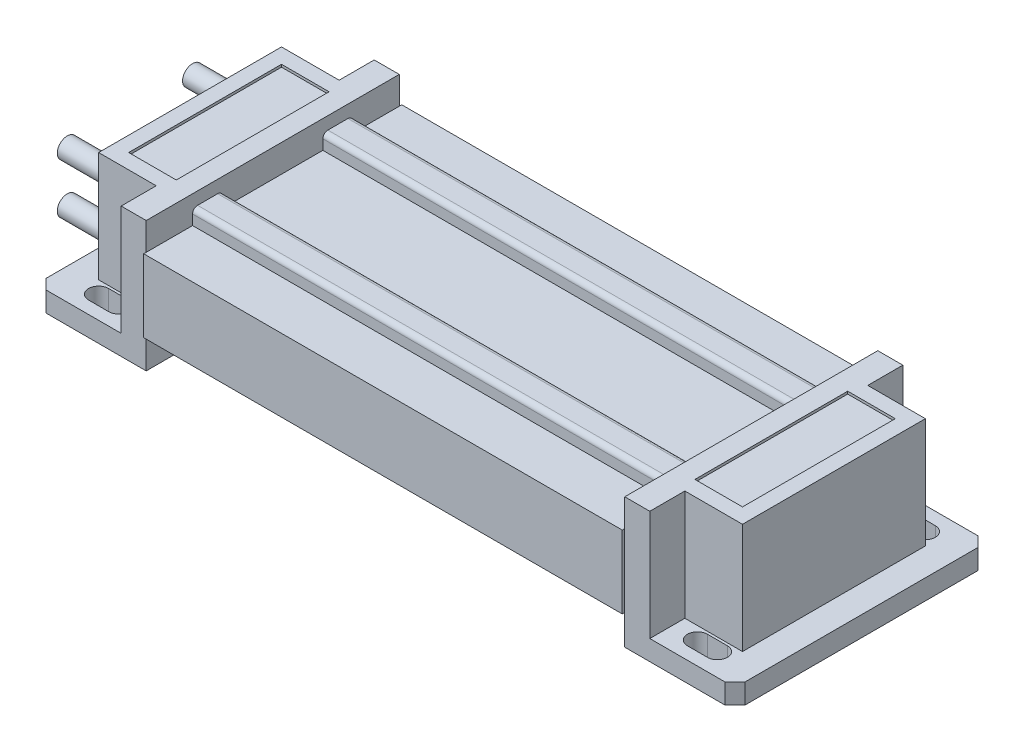
from build123d import *

# Parameters (mm, degrees)
SKETCH1_W             = 22
SKETCH1_H             = 50.5
BOSS_EXTRUDE1_DEPTH   = 26
BOSS_EXTRUDE1_2_DEPTH = 26
CHAMFER1_SIZE         = 2
CUT_EXTRUDE4_DEPTH    = 22
CHAMFER2_SIZE         = 2
SKETCH5_W             = 9.5
SKETCH5_H             = 30.5
CUT_EXTRUDE5_DEPTH    = 0.5
SKETCH6_W             = 51.5
SKETCH6_H             = 20.5
BOSS_EXTRUDE2_DEPTH   = 95.5
SKETCH7_R             = 2
BOSS_EXTRUDE3_DEPTH   = 12
CUT_EXTRUDE7_DEPTH    = 5
SKETCH15_W            = 95.5
SKETCH15_H            = 20
SKETCH15_H_2          = 9.75
CUT_EXTRUDE8_DEPTH    = 3
FILLET3_R             = 1
SKETCH16_W            = 95.5
SKETCH16_H            = 9.75
SKETCH16_H_2          = 20
CUT_EXTRUDE9_DEPTH    = 3
FILLET4_R             = 1
CUT_EXTRUDE10_DEPTH   = 0.1


with BuildPart() as part:
    # Sketch1 → Boss-Extrude1 (new body)
    with BuildSketch(Plane(origin=(0, 0, 0), x_dir=(1, 0, 0), z_dir=(0, 1, 0))):
        with Locations((11, 25.25)):
            Rectangle(SKETCH1_W, SKETCH1_H)
    extrude(amount=BOSS_EXTRUDE1_DEPTH)

    # Chamfer1
    chamfer1_edges = [part.edges().sort_by_distance(p)[0] for p in [
        (22, 13, -50.5),
        (22, 13, 0),
    ]]
    chamfer(chamfer1_edges, length=CHAMFER1_SIZE)


with BuildPart() as body_2:
    # Sketch1 → Boss-Extrude1 2 (new body)
    with BuildSketch(Plane(origin=(0, 0, 0), x_dir=(1, 0, 0), z_dir=(0, 1, 0))):
        with Locations((-106.5, 25.25)):
            Rectangle(SKETCH1_W, SKETCH1_H)
    extrude(amount=BOSS_EXTRUDE1_2_DEPTH)


with BuildPart() as cut_extrude4_tool:
    # Sketch2 → Cut-Extrude4 (new body)
    with BuildSketch(Plane(origin=(0, 26, 0), x_dir=(1, 0, 0), z_dir=(0, 1, 0))):
        Polygon((22, 50.5), (5, 50.5), (5, 43.5), (16.5, 43.5), (16.5, 7), (5, 7), (5, 0), (22, 0), align=None)
        Polygon((-117.5, 0), (-117.5, 50.5), (-100.5, 50.5), (-100.5, 43.5), (-112, 43.5), (-112, 7), (-100.5, 7), (-100.5, 0), align=None)
    extrude(amount=-CUT_EXTRUDE4_DEPTH)


with BuildPart() as part_1:
    add(part.part)

    # Cut-Extrude4: cut by cut_extrude4_tool
    add(cut_extrude4_tool.part, mode=Mode.SUBTRACT)


with BuildPart() as body_2_1:
    add(body_2.part)

    # Cut-Extrude4: cut by cut_extrude4_tool
    add(cut_extrude4_tool.part, mode=Mode.SUBTRACT)

    # Chamfer2
    chamfer2_edges = [body_2_1.edges().sort_by_distance(p)[0] for p in [
        (-117.5, 2, 0),
        (-117.5, 2, -50.5),
    ]]
    chamfer(chamfer2_edges, length=CHAMFER2_SIZE)


with BuildPart() as cut_extrude5_tool:
    # Sketch5 → Cut-Extrude5 (new body)
    with BuildSketch(Plane(origin=(0, 26, 0), x_dir=(1, 0, 0), z_dir=(0, 1, 0))):
        with Locations((8.75, 25.25)):
            Rectangle(SKETCH5_W, SKETCH5_H)
        with Locations((-104.25, 25.25)):
            Rectangle(SKETCH5_W, SKETCH5_H)
    extrude(amount=-CUT_EXTRUDE5_DEPTH)


with BuildPart() as part_2:
    add(part_1.part)

    # Cut-Extrude5: cut by cut_extrude5_tool
    add(cut_extrude5_tool.part, mode=Mode.SUBTRACT)



with BuildPart() as body_2_2:
    add(body_2_1.part)

    # Cut-Extrude5: cut by cut_extrude5_tool
    add(cut_extrude5_tool.part, mode=Mode.SUBTRACT)


with BuildPart() as part_3:
    add(part_2.part)

    add(body_2_2.part)  # Boss-Extrude2 merges body 2
    # Sketch6 → Boss-Extrude2 (add)
    with BuildSketch(Plane.ZY):
        with Locations((-25.25, 13.25)):
            Rectangle(SKETCH6_W, SKETCH6_H)
    extrude(amount=BOSS_EXTRUDE2_DEPTH)

    # Sketch7 → Boss-Extrude3 (add)
    with BuildSketch(Plane.ZY.offset(112)):
        with Locations((-37.75, 18)):
            Circle(SKETCH7_R)
        with Locations((-37.75, 8)):
            Circle(SKETCH7_R)
        with Locations((-12.75, 8)):
            Circle(SKETCH7_R)
        with Locations((-12.75, 18)):
            Circle(SKETCH7_R)
    extrude(amount=BOSS_EXTRUDE3_DEPTH)

    # Sketch14 → Cut-Extrude7 (cut, through all)
    with BuildSketch(Plane(origin=(0, 4, 0), x_dir=(1, 0, 0), z_dir=(0, 1, 0))):
        with BuildLine():
            Line((10, 6.5), (14, 6.5))
            ThreePointArc((14, 6.5), (16, 4.5), (14, 2.5))
            Line((14, 2.5), (10, 2.5))
            ThreePointArc((10, 2.5), (8, 4.5), (10, 6.5))
        make_face()
        with BuildLine():
            Line((14, 48), (10, 48))
            ThreePointArc((10, 48), (8, 46), (10, 44))
            Line((10, 44), (14, 44))
            ThreePointArc((14, 44), (16, 46), (14, 48))
        make_face()
        with BuildLine():
            Line((-105.5, 44), (-109.5, 44))
            ThreePointArc((-109.5, 44), (-111.5, 46), (-109.5, 48))
            Line((-109.5, 48), (-105.5, 48))
            ThreePointArc((-105.5, 48), (-103.5, 46), (-105.5, 44))
        make_face()
        with BuildLine():
            Line((-109.5, 2.5), (-105.5, 2.5))
            ThreePointArc((-105.5, 2.5), (-103.5, 4.5), (-105.5, 6.5))
            Line((-105.5, 6.5), (-109.5, 6.5))
            ThreePointArc((-109.5, 6.5), (-111.5, 4.5), (-109.5, 2.5))
        make_face()
    extrude(amount=-CUT_EXTRUDE7_DEPTH, mode=Mode.SUBTRACT)

    # Sketch15 → Cut-Extrude8 (cut)
    with BuildSketch(Plane(origin=(0, 23.5, 0), x_dir=(1, 0, 0), z_dir=(0, 1, 0))):
        with Locations((-47.75, 25.25)):
            Rectangle(SKETCH15_W, SKETCH15_H)
        with Locations((-47.75, 46.125)):
            Rectangle(SKETCH15_W, SKETCH15_H_2)
        with Locations((-47.75, 4.375)):
            Rectangle(SKETCH15_W, SKETCH15_H_2)
    extrude(amount=-CUT_EXTRUDE8_DEPTH, mode=Mode.SUBTRACT)

    # Fillet3
    fillet3_edges = [part_3.edges().sort_by_distance(p)[0] for p in [
        (-47.75, 23.5, -9.25),
        (-47.75, 23.5, -41.25),
        (-47.75, 23.5, -15.25),
        (-47.75, 23.5, -35.25),
    ]]
    fillet(fillet3_edges, radius=FILLET3_R)

    # Sketch16 → Cut-Extrude9 (cut)
    with BuildSketch(Plane.XZ.offset(-3)):
        with Locations((-47.75, -4.375)):
            Rectangle(SKETCH16_W, SKETCH16_H)
        with Locations((-47.75, -25.25)):
            Rectangle(SKETCH16_W, SKETCH16_H_2)
        with Locations((-47.75, -46.125)):
            Rectangle(SKETCH16_W, SKETCH16_H)
    extrude(amount=-CUT_EXTRUDE9_DEPTH, mode=Mode.SUBTRACT)

    # Fillet4
    fillet4_edges = [part_3.edges().sort_by_distance(p)[0] for p in [
        (-47.75, 3, -9.25),
        (-47.75, 3, -15.25),
        (-47.75, 3, -35.25),
        (-47.75, 3, -41.25),
    ]]
    fillet(fillet4_edges, radius=FILLET4_R)

    # Sketch17 → Cut-Extrude10 (cut)
    with BuildSketch(Plane(origin=(0, 0, -51), x_dir=(-1, 0, 0), z_dir=(0, 0, -1))):
        Polygon((27.949136007, 14.272391854), (28.842365174, 14.272391854), (28.842365174, 10.772391854), (28.393647225, 10.772391854), (28.393647225, 13.913417495), (27.675698507, 13.913417495), align=None)
        Polygon((32.490161648, 14.272391854), (33.383390815, 14.272391854), (33.383390815, 10.772391854), (32.934672866, 10.772391854), (32.934672866, 13.913417495), (32.216724148, 13.913417495), align=None)
        with BuildLine():
            add(Edge.make_bspline(
                [(36.039801071, 12.520989611), (36.040235983, 12.577094028), (36.041081058, 12.68611009), (36.050574892, 12.844910803), (36.064868155, 12.993962436), (36.085180208, 13.133192187), (36.110637379, 13.262589071), (36.143023474, 13.381959165), (36.180368413, 13.49196332), (36.225174876, 13.592138896), (36.274712189, 13.684710107), (36.328469097, 13.771188768), (36.38799451, 13.851434251), (36.45138155, 13.926720723), (36.52062727, 13.995281683), (36.593483365, 14.059255742), (36.672666025, 14.115462843), (36.755053625, 14.167883856), (36.842062471, 14.212770811), (36.931049243, 14.253052657), (37.022816498, 14.287065778), (37.117416889, 14.313958722), (37.214249595, 14.336003342), (37.313575351, 14.351316575), (37.415450847, 14.360724191), (37.484325108, 14.361661345), (37.519168058, 14.362135444)],
                knots=[0, 0, 0, 0, 0.000168293, 0.000327008, 0.000477071, 0.000617374, 0.000748963, 0.00087244, 0.000988183, 0.0010971, 0.001201238, 0.00130298, 0.001402263, 0.001500745, 0.001597915, 0.001694344, 0.001791254, 0.001888909, 0.001987068, 0.002084668, 0.002181828, 0.00228035, 0.002379516, 0.002479571, 0.002581641, 0.002686146, 0.002686146, 0.002686146, 0.002686146], degree=3))
            add(Edge.make_bspline(
                [(37.519168058, 14.362135444), (37.554478547, 14.36166435), (37.624286205, 14.360733013), (37.727785254, 14.351257617), (37.82875767, 14.336062357), (37.927025202, 14.314092082), (38.022899073, 14.286801802), (38.116177667, 14.253173476), (38.207012175, 14.212974768), (38.294994804, 14.166718619), (38.38028797, 14.115300464), (38.460035266, 14.056036025), (38.53531424, 13.991199698), (38.606734448, 13.920830483), (38.673025877, 13.843712168), (38.734978515, 13.760466194), (38.792618744, 13.671362711), (38.845184505, 13.575494404), (38.893631875, 13.472962641), (38.933694767, 13.361411477), (38.968875408, 13.242086643), (38.997662627, 13.114243633), (39.018784732, 12.977612284), (39.035179767, 12.832859287), (39.043915908, 12.679550087), (39.045433031, 12.574751944), (39.046211327, 12.520989611)],
                knots=[0, 0, 0, 0, 0.000105907, 0.000209374, 0.000311507, 0.000412041, 0.000511237, 0.000610373, 0.000709254, 0.000808981, 0.000908424, 0.001007706, 0.001106644, 0.001206295, 0.001308199, 0.001411404, 0.001517394, 0.001626285, 0.001739207, 0.001857212, 0.001981452, 0.002112254, 0.002249997, 0.002396022, 0.002549138, 0.002710434, 0.002710434, 0.002710434, 0.002710434], degree=3))
            add(Edge.make_bspline(
                [(39.046211327, 12.520989611), (39.045843029, 12.467451311), (39.045125059, 12.363082493), (39.034618126, 12.210608827), (39.019851972, 12.066399915), (38.998088561, 11.930638042), (38.970361122, 11.803398042), (38.935621992, 11.684616104), (38.896604041, 11.573415137), (38.848672365, 11.471409879), (38.796826082, 11.376236328), (38.739730755, 11.287542192), (38.677963516, 11.204542607), (38.611382143, 11.127489786), (38.540424072, 11.056160101), (38.464198069, 10.991556436), (38.383588229, 10.932368046), (38.298157294, 10.880186788), (38.20946177, 10.833950919), (38.118465766, 10.792785454), (38.024144578, 10.759635101), (37.928067591, 10.731275118), (37.829447857, 10.709416769), (37.728218641, 10.694402009), (37.624558946, 10.683843515), (37.554484796, 10.683048796), (37.519168058, 10.682648264)],
                knots=[0, 0, 0, 0, 0.000160581, 0.000313041, 0.000458294, 0.000595344, 0.000725309, 0.000848679, 0.000966444, 0.001078435, 0.001186374, 0.001291395, 0.0013946, 0.001496505, 0.00159665, 0.00169612, 0.001795968, 0.001896375, 0.001996102, 0.002095908, 0.002195704, 0.002295768, 0.002396303, 0.002498436, 0.002602665, 0.002708572, 0.002708572, 0.002708572, 0.002708572], degree=3))
            add(Edge.make_bspline(
                [(37.519168058, 10.682648264), (37.484325774, 10.683125714), (37.41545283, 10.684069492), (37.313567698, 10.693428635), (37.214553182, 10.708878131), (37.118139153, 10.730115006), (37.023897476, 10.756267868), (36.93279393, 10.790349307), (36.844150014, 10.829852623), (36.75790675, 10.874148524), (36.675929863, 10.925708301), (36.597686563, 10.98232147), (36.524517882, 11.045912111), (36.456117601, 11.115277112), (36.391673175, 11.18988494), (36.332814932, 11.27106257), (36.278164698, 11.357917396), (36.227981112, 11.451238123), (36.182517558, 11.552110179), (36.144209784, 11.662686304), (36.112348706, 11.782788589), (36.085891276, 11.912029559), (36.064673116, 12.050760286), (36.050630588, 12.199177667), (36.041078698, 12.357035513), (36.040234632, 12.465351995), (36.039801071, 12.520989611)],
                knots=[0, 0, 0, 0, 0.000104505, 0.000206575, 0.000306629, 0.000404959, 0.000502614, 0.000599775, 0.000696448, 0.000793662, 0.00089035, 0.000986693, 0.001083122, 0.001180789, 0.001278738, 0.001378586, 0.001481295, 0.001586381, 0.001696225, 0.00181286, 0.001937014, 0.002068743, 0.002208456, 0.002357822, 0.002515837, 0.002682728, 0.002682728, 0.002682728, 0.002682728], degree=3))
        make_face()
        with BuildLine():
            add(Edge.make_bspline(
                [(36.48851902, 12.522391854), (36.488875922, 12.475641221), (36.489568659, 12.384899615), (36.496236038, 12.253043074), (36.505507206, 12.129969204), (36.519547326, 12.015797558), (36.537514851, 11.910430975), (36.559943295, 11.813801107), (36.585421525, 11.725726689), (36.615978361, 11.646118476), (36.65072469, 11.573506871), (36.688634644, 11.50563237), (36.730689437, 11.442650123), (36.776472473, 11.383904049), (36.82647001, 11.330046385), (36.879661382, 11.27978636), (36.937554696, 11.23506405), (37.018331151, 11.181193314), (37.1245234, 11.125503043), (37.257567413, 11.077478682), (37.394194569, 11.047352586), (37.486765943, 11.043536427), (37.533190494, 11.041622623)],
                knots=[0, 0, 0, 0, 0.00014024, 0.000272202, 0.000395989, 0.000510433, 0.00061717, 0.000716492, 0.000807891, 0.000892005, 0.000971976, 0.001049201, 0.001125039, 0.001198953, 0.001272387, 0.001345307, 0.001418237, 0.001491547, 0.001636436, 0.001776604, 0.00191494, 0.002054109, 0.002054109, 0.002054109, 0.002054109], degree=3))
            add(Edge.make_bspline(
                [(37.533190494, 11.041622623), (37.579859929, 11.043210831), (37.672703306, 11.046370383), (37.808643009, 11.07683322), (37.940297023, 11.123134292), (38.04431141, 11.177948226), (38.123227197, 11.230857823), (38.179979715, 11.27509567), (38.232226119, 11.325146024), (38.281423744, 11.379066057), (38.326954481, 11.437613567), (38.366899712, 11.501937143), (38.405580243, 11.569689922), (38.426841082, 11.617967849), (38.437637609, 11.642484002)],
                knots=[0, 0, 0, 0, 0.000139821, 0.000278157, 0.000415871, 0.000557625, 0.000629379, 0.000700773, 0.000773183, 0.000846143, 0.000919627, 0.000995287, 0.001073124, 0.001153432, 0.001153432, 0.001153432, 0.001153432], degree=3))
            add(Edge.make_bspline(
                [(38.437637609, 11.642484002), (38.450345588, 11.673676811), (38.476077088, 11.736836953), (38.509205296, 11.835237826), (38.536182429, 11.938417315), (38.558741933, 12.046045221), (38.576094621, 12.158391522), (38.588874622, 12.275577974), (38.595544538, 12.39751463), (38.596836766, 12.480317641), (38.597493379, 12.522391854)],
                knots=[0, 0, 0, 0, 0.000101032, 0.000204573, 0.000311203, 0.000420796, 0.000534337, 0.000652102, 0.000774299, 0.000900532, 0.000900532, 0.000900532, 0.000900532], degree=3))
            add(Edge.make_bspline(
                [(38.597493379, 12.522391854), (38.597172753, 12.564470465), (38.596545278, 12.646819833), (38.589221816, 12.767261289), (38.578202839, 12.881891439), (38.562750002, 12.990666929), (38.543593037, 13.09379738), (38.518722813, 13.190814503), (38.49039008, 13.282374208), (38.456360186, 13.367785626), (38.419645582, 13.447899513), (38.378347794, 13.521695563), (38.335373765, 13.591037782), (38.287341746, 13.653825663), (38.236926569, 13.712133433), (38.18200663, 13.763699569), (38.124391298, 13.810542334), (38.043464254, 13.863888807), (37.937914197, 13.919110503), (37.806481371, 13.968314473), (37.670687781, 13.997168234), (37.579128579, 14.001158863), (37.533190494, 14.003161085)],
                knots=[0, 0, 0, 0, 0.000126219, 0.000247016, 0.000361848, 0.000471611, 0.000576529, 0.000676347, 0.000771919, 0.000863838, 0.000951981, 0.001036084, 0.00111739, 0.001196477, 0.001272986, 0.001348369, 0.00142217, 0.00149548, 0.001638801, 0.001778551, 0.00191537, 0.00205314, 0.00205314, 0.00205314, 0.00205314], degree=3))
            add(Edge.make_bspline(
                [(37.533190494, 14.003161085), (37.486317378, 14.001182552), (37.393363215, 13.997258919), (37.255924816, 13.968413802), (37.123727747, 13.919277399), (37.018305746, 13.864007662), (36.938003323, 13.811214256), (36.881086978, 13.766093094), (36.827759883, 13.716456909), (36.778744732, 13.661750884), (36.731822285, 13.604067767), (36.691051453, 13.540066466), (36.651857171, 13.472963465), (36.617634736, 13.399862701), (36.585865013, 13.320651794), (36.560855123, 13.232557262), (36.537951282, 13.136044586), (36.520513995, 13.030317331), (36.505314649, 12.916040649), (36.496250342, 12.792669395), (36.48955915, 12.660586849), (36.488872654, 12.569376831), (36.48851902, 12.522391854)],
                knots=[0, 0, 0, 0, 0.000140567, 0.00027876, 0.000419168, 0.000562489, 0.000634827, 0.000707205, 0.000780125, 0.000853086, 0.000927434, 0.001002886, 0.001080457, 0.001160428, 0.001244796, 0.001336195, 0.001434834, 0.001542262, 0.001657489, 0.001780577, 0.001913239, 0.002054181, 0.002054181, 0.002054181, 0.002054181], degree=3))
        make_face(mode=Mode.SUBTRACT)
        Polygon((40.625698507, 14.272391854), (41.113679276, 14.272391854), (42.600057481, 11.576578553), (44.086435686, 14.272391854), (44.574416456, 14.272391854), (42.644929276, 10.772391854), (42.555185686, 10.772391854), align=None)
        with BuildLine():
            Line((51.726980558, 14.272391854), (51.726980558, 13.913417495))
            Line((51.726980558, 13.913417495), (50.251820302, 13.913417495))
            Line((50.251820302, 13.913417495), (50.014140013, 12.985132239))
            add(Edge.make_bspline(
                [(50.014140013, 12.985132239), (50.059359491, 12.996649671), (50.147190161, 13.019020204), (50.27666501, 13.042735849), (50.399408955, 13.057629766), (50.478945507, 13.059800104), (50.517545462, 13.060853393)],
                knots=[0, 0, 0, 0, 0.000139952, 0.000271832, 0.000394631, 0.00051042, 0.00051042, 0.00051042, 0.00051042], degree=3))
            add(Edge.make_bspline(
                [(50.517545462, 13.060853393), (50.565266355, 13.06001131), (50.658865196, 13.058359664), (50.795768939, 13.042455346), (50.92637733, 13.017298979), (51.050561443, 12.982408573), (51.168568881, 12.937492909), (51.279672913, 12.881710842), (51.384857528, 12.816339099), (51.482346489, 12.740916047), (51.57088404, 12.658088923), (51.649180464, 12.569350957), (51.714208913, 12.47404308), (51.769302538, 12.374021545), (51.810578196, 12.26730352), (51.839739731, 12.155065825), (51.85892229, 12.037404397), (51.860694136, 11.956896929), (51.861595943, 11.915921502)],
                knots=[0, 0, 0, 0, 0.000143113, 0.000280699, 0.00041284, 0.000541795, 0.000667186, 0.000791038, 0.000914185, 0.001038154, 0.001160178, 0.001277448, 0.001392385, 0.001505639, 0.001619303, 0.001734605, 0.001853103, 0.001975927, 0.001975927, 0.001975927, 0.001975927], degree=3))
            add(Edge.make_bspline(
                [(51.861595943, 11.915921502), (51.861188474, 11.88737687), (51.860377713, 11.8305803), (51.849835775, 11.746516668), (51.83460967, 11.663984), (51.813077303, 11.583141307), (51.783874905, 11.504669629), (51.749473557, 11.427697438), (51.708585842, 11.352526978), (51.66188973, 11.279492291), (51.610132824, 11.209232944), (51.553129431, 11.143422027), (51.49201874, 11.081295381), (51.425935432, 11.02393309), (51.355692268, 10.970501578), (51.281164209, 10.921399756), (51.202344509, 10.876225626), (51.118968451, 10.836035872), (51.03222174, 10.799082616), (50.941453195, 10.768849719), (50.847820942, 10.741654157), (50.750579996, 10.720285833), (50.650198858, 10.703334062), (50.546494813, 10.691757975), (50.439622739, 10.683437971), (50.367054696, 10.682913546), (50.330345943, 10.682648264)],
                knots=[0, 0, 0, 0, 8.5583e-05, 0.000170288, 0.000253757, 0.000337264, 0.000420886, 0.000504675, 0.000590008, 0.000677336, 0.000764557, 0.000851556, 0.000938317, 0.001025774, 0.001113837, 0.001202899, 0.001293341, 0.001386157, 0.001480431, 0.001575992, 0.001672973, 0.001772823, 0.001874486, 0.001978237, 0.002085786, 0.002195882, 0.002195882, 0.002195882, 0.002195882], degree=3))
            add(Edge.make_bspline(
                [(50.330345943, 10.682648264), (50.286600229, 10.683329509), (50.200766702, 10.684666181), (50.074833572, 10.698926259), (49.9538945, 10.719078003), (49.838276798, 10.749928902), (49.727385735, 10.787718255), (49.622576005, 10.83628061), (49.522242352, 10.891537029), (49.428174587, 10.955711207), (49.341552574, 11.027264137), (49.262670069, 11.103444508), (49.193194346, 11.185151489), (49.134601717, 11.272742935), (49.083305316, 11.364309131), (49.0420078, 11.461363894), (49.010023336, 11.56357704), (48.996592979, 11.634142082), (48.989801071, 11.669827752)],
                knots=[0, 0, 0, 0, 0.000131177, 0.000257383, 0.000379797, 0.000498667, 0.000615964, 0.000730796, 0.000844726, 0.000959267, 0.00107184, 0.001181415, 0.001287884, 0.001392893, 0.001497084, 0.001602311, 0.001708757, 0.001817664, 0.001817664, 0.001817664, 0.001817664], degree=3))
            Line((48.989801071, 11.669827752), (49.43851902, 11.669827752))
            add(Edge.make_bspline(
                [(49.43851902, 11.669827752), (49.447755043, 11.636365261), (49.46560646, 11.571688846), (49.505008566, 11.481709867), (49.551742015, 11.400826101), (49.608776128, 11.329528476), (49.675954757, 11.267295097), (49.752497267, 11.211851428), (49.83838453, 11.161576549), (49.933973886, 11.11993857), (50.035039002, 11.084642296), (50.140433609, 11.060616975), (50.247797397, 11.044165571), (50.320468079, 11.042473147), (50.356988571, 11.041622623)],
                knots=[0, 0, 0, 0, 0.000104024, 0.000201058, 0.000293768, 0.000383555, 0.000473834, 0.000567651, 0.000666618, 0.000771763, 0.000879963, 0.000987274, 0.001095649, 0.001205134, 0.001205134, 0.001205134, 0.001205134], degree=3))
            add(Edge.make_bspline(
                [(50.356988571, 11.041622623), (50.392548066, 11.042453009), (50.462699598, 11.04409119), (50.565833665, 11.056389306), (50.665233157, 11.075530796), (50.760128315, 11.104316395), (50.852193517, 11.138811428), (50.939403366, 11.183617961), (51.023682982, 11.234620137), (51.10198434, 11.294239746), (51.174803989, 11.358407547), (51.238223493, 11.428436231), (51.292713308, 11.501837225), (51.336390268, 11.580029003), (51.371325122, 11.661395025), (51.394786802, 11.747327289), (51.4102519, 11.836837021), (51.411992749, 11.89809321), (51.412877994, 11.929242816)],
                knots=[0, 0, 0, 0, 0.000106654, 0.000210405, 0.000311194, 0.000409913, 0.000507568, 0.00060571, 0.000703591, 0.00080273, 0.000900548, 0.000994354, 0.001085646, 0.001174176, 0.001262465, 0.001350586, 0.001440837, 0.001534216, 0.001534216, 0.001534216, 0.001534216], degree=3))
            add(Edge.make_bspline(
                [(51.412877994, 11.929242816), (51.412175192, 11.957347693), (51.410796362, 12.01248672), (51.396833878, 12.092885514), (51.37539532, 12.169327993), (51.344045455, 12.241576554), (51.303879314, 12.309754059), (51.255078701, 12.373892948), (51.197835412, 12.434016255), (51.13177126, 12.488830137), (51.059198779, 12.539476703), (50.979488392, 12.583149236), (50.893570291, 12.618886281), (50.802855157, 12.650694093), (50.705418953, 12.673101892), (50.602411041, 12.690068172), (50.493424556, 12.699772763), (50.418939371, 12.701166093), (50.380826712, 12.701879034)],
                knots=[0, 0, 0, 0, 8.424e-05, 0.00016527, 0.000244049, 0.000321933, 0.000400815, 0.000480884, 0.000563206, 0.000649295, 0.000737981, 0.00082835, 0.000921332, 0.001016893, 0.001116376, 0.001220805, 0.001329922, 0.001444258, 0.001444258, 0.001444258, 0.001444258], degree=3))
            add(Edge.make_bspline(
                [(50.380826712, 12.701879034), (50.347624231, 12.701304974), (50.279250603, 12.700122819), (50.174199853, 12.691228194), (50.064027435, 12.677184284), (49.948754933, 12.657302211), (49.828319476, 12.632047297), (49.702786423, 12.601038166), (49.572088388, 12.564535654), (49.483780232, 12.536672669), (49.43851902, 12.522391854)],
                knots=[0, 0, 0, 0, 9.9599e-05, 0.000205103, 0.000316069, 0.000432717, 0.000555923, 0.000685159, 0.000820568, 0.000962943, 0.000962943, 0.000962943, 0.000962943], degree=3))
            Line((49.43851902, 12.522391854), (49.887236968, 14.272391854))
            Line((49.887236968, 14.272391854), (51.726980558, 14.272391854))
        make_face()
        with BuildLine():
            add(Edge.make_bspline(
                [(53.441083122, 12.520989611), (53.441518035, 12.577094028), (53.44236311, 12.68611009), (53.451856943, 12.844910803), (53.466150206, 12.993962436), (53.486462259, 13.133192187), (53.51191943, 13.262589071), (53.544305525, 13.381959165), (53.581650464, 13.49196332), (53.626456927, 13.592138896), (53.67599424, 13.684710107), (53.729751148, 13.771188768), (53.789276561, 13.851434251), (53.852663601, 13.926720723), (53.921909321, 13.995281683), (53.994765417, 14.059255742), (54.073948076, 14.115462843), (54.156335677, 14.167883856), (54.243344522, 14.212770811), (54.332331294, 14.253052657), (54.424098549, 14.287065778), (54.51869894, 14.313958722), (54.615531647, 14.336003342), (54.714857402, 14.351316575), (54.816732898, 14.360724191), (54.885607159, 14.361661345), (54.920450109, 14.362135444)],
                knots=[0, 0, 0, 0, 0.000168293, 0.000327008, 0.000477071, 0.000617374, 0.000748963, 0.00087244, 0.000988183, 0.0010971, 0.001201238, 0.00130298, 0.001402263, 0.001500745, 0.001597915, 0.001694344, 0.001791254, 0.001888909, 0.001987068, 0.002084668, 0.002181828, 0.00228035, 0.002379516, 0.002479571, 0.002581641, 0.002686146, 0.002686146, 0.002686146, 0.002686146], degree=3))
            add(Edge.make_bspline(
                [(54.920450109, 14.362135444), (54.955760598, 14.36166435), (55.025568256, 14.360733013), (55.129067305, 14.351257617), (55.230039722, 14.336062357), (55.328307253, 14.314092082), (55.424181125, 14.286801802), (55.517459719, 14.253173476), (55.608294227, 14.212974768), (55.696276856, 14.166718619), (55.781570021, 14.115300464), (55.861317318, 14.056036025), (55.936596292, 13.991199698), (56.008016499, 13.920830483), (56.074307928, 13.843712168), (56.136260566, 13.760466194), (56.193900795, 13.671362711), (56.246466557, 13.575494404), (56.294913926, 13.472962641), (56.334976818, 13.361411477), (56.370157459, 13.242086643), (56.398944678, 13.114243633), (56.420066784, 12.977612284), (56.436461818, 12.832859287), (56.44519796, 12.679550087), (56.446715082, 12.574751944), (56.447493379, 12.520989611)],
                knots=[0, 0, 0, 0, 0.000105907, 0.000209374, 0.000311507, 0.000412041, 0.000511237, 0.000610373, 0.000709254, 0.000808981, 0.000908424, 0.001007706, 0.001106644, 0.001206295, 0.001308199, 0.001411404, 0.001517394, 0.001626285, 0.001739207, 0.001857212, 0.001981452, 0.002112254, 0.002249997, 0.002396022, 0.002549138, 0.002710434, 0.002710434, 0.002710434, 0.002710434], degree=3))
            add(Edge.make_bspline(
                [(56.447493379, 12.520989611), (56.44712508, 12.467451311), (56.44640711, 12.363082493), (56.435900178, 12.210608827), (56.421134023, 12.066399915), (56.399370613, 11.930638042), (56.371643173, 11.803398042), (56.336904043, 11.684616104), (56.297886092, 11.573415137), (56.249954416, 11.471409879), (56.198108133, 11.376236328), (56.141012806, 11.287542192), (56.079245567, 11.204542607), (56.012664194, 11.127489786), (55.941706123, 11.056160101), (55.86548012, 10.991556436), (55.78487028, 10.932368046), (55.699439345, 10.880186788), (55.610743821, 10.833950919), (55.519747817, 10.792785454), (55.425426629, 10.759635101), (55.329349642, 10.731275118), (55.230729908, 10.709416769), (55.129500692, 10.694402009), (55.025840998, 10.683843515), (54.955766847, 10.683048796), (54.920450109, 10.682648264)],
                knots=[0, 0, 0, 0, 0.000160581, 0.000313041, 0.000458294, 0.000595344, 0.000725309, 0.000848679, 0.000966444, 0.001078435, 0.001186374, 0.001291395, 0.0013946, 0.001496505, 0.00159665, 0.00169612, 0.001795968, 0.001896375, 0.001996102, 0.002095908, 0.002195704, 0.002295768, 0.002396303, 0.002498436, 0.002602665, 0.002708572, 0.002708572, 0.002708572, 0.002708572], degree=3))
            add(Edge.make_bspline(
                [(54.920450109, 10.682648264), (54.885607825, 10.683125714), (54.816734881, 10.684069492), (54.71484975, 10.693428635), (54.615835233, 10.708878131), (54.519421204, 10.730115006), (54.425179527, 10.756267868), (54.334075981, 10.790349307), (54.245432065, 10.829852623), (54.159188801, 10.874148524), (54.077211914, 10.925708301), (53.998968614, 10.98232147), (53.925799933, 11.045912111), (53.857399652, 11.115277112), (53.792955226, 11.18988494), (53.734096984, 11.27106257), (53.679446749, 11.357917396), (53.629263163, 11.451238123), (53.583799609, 11.552110179), (53.545491836, 11.662686304), (53.513630757, 11.782788589), (53.487173327, 11.912029559), (53.465955167, 12.050760286), (53.451912639, 12.199177667), (53.442360749, 12.357035513), (53.441516683, 12.465351995), (53.441083122, 12.520989611)],
                knots=[0, 0, 0, 0, 0.000104505, 0.000206575, 0.000306629, 0.000404959, 0.000502614, 0.000599775, 0.000696448, 0.000793662, 0.00089035, 0.000986693, 0.001083122, 0.001180789, 0.001278738, 0.001378586, 0.001481295, 0.001586381, 0.001696225, 0.00181286, 0.001937014, 0.002068743, 0.002208456, 0.002357822, 0.002515837, 0.002682728, 0.002682728, 0.002682728, 0.002682728], degree=3))
        make_face()
        with BuildLine():
            add(Edge.make_bspline(
                [(53.889801071, 12.522391854), (53.890157973, 12.475641221), (53.890850711, 12.384899615), (53.897518089, 12.253043074), (53.906789257, 12.129969204), (53.920829377, 12.015797558), (53.938796902, 11.910430975), (53.961225346, 11.813801107), (53.986703576, 11.725726689), (54.017260412, 11.646118476), (54.052006742, 11.573506871), (54.089916695, 11.50563237), (54.131971488, 11.442650123), (54.177754524, 11.383904049), (54.227752061, 11.330046385), (54.280943434, 11.27978636), (54.338836747, 11.23506405), (54.419613203, 11.181193314), (54.525805452, 11.125503043), (54.658849464, 11.077478682), (54.79547662, 11.047352586), (54.888047994, 11.043536427), (54.934472545, 11.041622623)],
                knots=[0, 0, 0, 0, 0.00014024, 0.000272202, 0.000395989, 0.000510433, 0.00061717, 0.000716492, 0.000807891, 0.000892005, 0.000971976, 0.001049201, 0.001125039, 0.001198953, 0.001272387, 0.001345307, 0.001418237, 0.001491547, 0.001636436, 0.001776604, 0.00191494, 0.002054109, 0.002054109, 0.002054109, 0.002054109], degree=3))
            add(Edge.make_bspline(
                [(54.934472545, 11.041622623), (54.981141981, 11.043210831), (55.073985358, 11.046370383), (55.20992506, 11.07683322), (55.341579074, 11.123134292), (55.445593461, 11.177948226), (55.524509248, 11.230857823), (55.581261766, 11.27509567), (55.63350817, 11.325146024), (55.682705795, 11.379066057), (55.728236532, 11.437613567), (55.768181763, 11.501937143), (55.806862294, 11.569689922), (55.828123133, 11.617967849), (55.838919661, 11.642484002)],
                knots=[0, 0, 0, 0, 0.000139821, 0.000278157, 0.000415871, 0.000557625, 0.000629379, 0.000700773, 0.000773183, 0.000846143, 0.000919627, 0.000995287, 0.001073124, 0.001153432, 0.001153432, 0.001153432, 0.001153432], degree=3))
            add(Edge.make_bspline(
                [(55.838919661, 11.642484002), (55.85162764, 11.673676811), (55.877359139, 11.736836953), (55.910487347, 11.835237826), (55.93746448, 11.938417315), (55.960023984, 12.046045221), (55.977376673, 12.158391522), (55.990156674, 12.275577974), (55.996826589, 12.39751463), (55.998118818, 12.480317641), (55.99877543, 12.522391854)],
                knots=[0, 0, 0, 0, 0.000101032, 0.000204573, 0.000311203, 0.000420796, 0.000534337, 0.000652102, 0.000774299, 0.000900532, 0.000900532, 0.000900532, 0.000900532], degree=3))
            add(Edge.make_bspline(
                [(55.99877543, 12.522391854), (55.998454805, 12.564470465), (55.997827329, 12.646819833), (55.990503868, 12.767261289), (55.97948489, 12.881891439), (55.964032054, 12.990666929), (55.944875088, 13.09379738), (55.920004864, 13.190814503), (55.891672132, 13.282374208), (55.857642237, 13.367785626), (55.820927634, 13.447899513), (55.779629846, 13.521695563), (55.736655816, 13.591037782), (55.688623797, 13.653825663), (55.63820862, 13.712133433), (55.583288681, 13.763699569), (55.525673349, 13.810542334), (55.444746305, 13.863888807), (55.339196249, 13.919110503), (55.207763423, 13.968314473), (55.071969832, 13.997168234), (54.980410631, 14.001158863), (54.934472545, 14.003161085)],
                knots=[0, 0, 0, 0, 0.000126219, 0.000247016, 0.000361848, 0.000471611, 0.000576529, 0.000676347, 0.000771919, 0.000863838, 0.000951981, 0.001036084, 0.00111739, 0.001196477, 0.001272986, 0.001348369, 0.00142217, 0.00149548, 0.001638801, 0.001778551, 0.00191537, 0.00205314, 0.00205314, 0.00205314, 0.00205314], degree=3))
            add(Edge.make_bspline(
                [(54.934472545, 14.003161085), (54.887599429, 14.001182552), (54.794645267, 13.997258919), (54.657206867, 13.968413802), (54.525009798, 13.919277399), (54.419587797, 13.864007662), (54.339285374, 13.811214256), (54.282369029, 13.766093094), (54.229041935, 13.716456909), (54.180026783, 13.661750884), (54.133104336, 13.604067767), (54.092333504, 13.540066466), (54.053139223, 13.472963465), (54.018916787, 13.399862701), (53.987147065, 13.320651794), (53.962137174, 13.232557262), (53.939233333, 13.136044586), (53.921796046, 13.030317331), (53.9065967, 12.916040649), (53.897532393, 12.792669395), (53.890841201, 12.660586849), (53.890154705, 12.569376831), (53.889801071, 12.522391854)],
                knots=[0, 0, 0, 0, 0.000140567, 0.00027876, 0.000419168, 0.000562489, 0.000634827, 0.000707205, 0.000780125, 0.000853086, 0.000927434, 0.001002886, 0.001080457, 0.001160428, 0.001244796, 0.001336195, 0.001434834, 0.001542262, 0.001657489, 0.001780577, 0.001913239, 0.002054181, 0.002054181, 0.002054181, 0.002054181], degree=3))
        make_face(mode=Mode.SUBTRACT)
        with BuildLine():
            add(Edge.make_bspline(
                [(57.982108763, 12.520989611), (57.982543676, 12.577094028), (57.983388751, 12.68611009), (57.992882584, 12.844910803), (58.007175847, 12.993962436), (58.0274879, 13.133192187), (58.052945071, 13.262589071), (58.085331166, 13.381959165), (58.122676105, 13.49196332), (58.167482568, 13.592138896), (58.217019881, 13.684710107), (58.270776789, 13.771188768), (58.330302202, 13.851434251), (58.393689242, 13.926720723), (58.462934962, 13.995281683), (58.535791058, 14.059255742), (58.614973717, 14.115462843), (58.697361318, 14.167883856), (58.784370163, 14.212770811), (58.873356935, 14.253052657), (58.96512419, 14.287065778), (59.059724581, 14.313958722), (59.156557288, 14.336003342), (59.255883043, 14.351316575), (59.357758539, 14.360724191), (59.4266328, 14.361661345), (59.46147575, 14.362135444)],
                knots=[0, 0, 0, 0, 0.000168293, 0.000327008, 0.000477071, 0.000617374, 0.000748963, 0.00087244, 0.000988183, 0.0010971, 0.001201238, 0.00130298, 0.001402263, 0.001500745, 0.001597915, 0.001694344, 0.001791254, 0.001888909, 0.001987068, 0.002084668, 0.002181828, 0.00228035, 0.002379516, 0.002479571, 0.002581641, 0.002686146, 0.002686146, 0.002686146, 0.002686146], degree=3))
            add(Edge.make_bspline(
                [(59.46147575, 14.362135444), (59.496786239, 14.36166435), (59.566593897, 14.360733013), (59.670092946, 14.351257617), (59.771065363, 14.336062357), (59.869332894, 14.314092082), (59.965206766, 14.286801802), (60.05848536, 14.253173476), (60.149319868, 14.212974768), (60.237302497, 14.166718619), (60.322595662, 14.115300464), (60.402342959, 14.056036025), (60.477621933, 13.991199698), (60.54904214, 13.920830483), (60.615333569, 13.843712168), (60.677286207, 13.760466194), (60.734926436, 13.671362711), (60.787492198, 13.575494404), (60.835939567, 13.472962641), (60.876002459, 13.361411477), (60.9111831, 13.242086643), (60.939970319, 13.114243633), (60.961092425, 12.977612284), (60.977487459, 12.832859287), (60.986223601, 12.679550087), (60.987740723, 12.574751944), (60.98851902, 12.520989611)],
                knots=[0, 0, 0, 0, 0.000105907, 0.000209374, 0.000311507, 0.000412041, 0.000511237, 0.000610373, 0.000709254, 0.000808981, 0.000908424, 0.001007706, 0.001106644, 0.001206295, 0.001308199, 0.001411404, 0.001517394, 0.001626285, 0.001739207, 0.001857212, 0.001981452, 0.002112254, 0.002249997, 0.002396022, 0.002549138, 0.002710434, 0.002710434, 0.002710434, 0.002710434], degree=3))
            add(Edge.make_bspline(
                [(60.98851902, 12.520989611), (60.988150721, 12.467451311), (60.987432751, 12.363082493), (60.976925819, 12.210608827), (60.962159664, 12.066399915), (60.940396254, 11.930638042), (60.912668814, 11.803398042), (60.877929684, 11.684616104), (60.838911733, 11.573415137), (60.790980057, 11.471409879), (60.739133775, 11.376236328), (60.682038447, 11.287542192), (60.620271208, 11.204542607), (60.553689835, 11.127489786), (60.482731764, 11.056160101), (60.406505761, 10.991556436), (60.325895921, 10.932368046), (60.240464986, 10.880186788), (60.151769462, 10.833950919), (60.060773458, 10.792785454), (59.96645227, 10.759635101), (59.870375283, 10.731275118), (59.771755549, 10.709416769), (59.670526333, 10.694402009), (59.566866639, 10.683843515), (59.496792488, 10.683048796), (59.46147575, 10.682648264)],
                knots=[0, 0, 0, 0, 0.000160581, 0.000313041, 0.000458294, 0.000595344, 0.000725309, 0.000848679, 0.000966444, 0.001078435, 0.001186374, 0.001291395, 0.0013946, 0.001496505, 0.00159665, 0.00169612, 0.001795968, 0.001896375, 0.001996102, 0.002095908, 0.002195704, 0.002295768, 0.002396303, 0.002498436, 0.002602665, 0.002708572, 0.002708572, 0.002708572, 0.002708572], degree=3))
            add(Edge.make_bspline(
                [(59.46147575, 10.682648264), (59.426633466, 10.683125714), (59.357760522, 10.684069492), (59.255875391, 10.693428635), (59.156860874, 10.708878131), (59.060446845, 10.730115006), (58.966205168, 10.756267868), (58.875101622, 10.790349307), (58.786457706, 10.829852623), (58.700214442, 10.874148524), (58.618237555, 10.925708301), (58.539994255, 10.98232147), (58.466825574, 11.045912111), (58.398425293, 11.115277112), (58.333980868, 11.18988494), (58.275122625, 11.27106257), (58.22047239, 11.357917396), (58.170288804, 11.451238123), (58.12482525, 11.552110179), (58.086517477, 11.662686304), (58.054656398, 11.782788589), (58.028198968, 11.912029559), (58.006980808, 12.050760286), (57.99293828, 12.199177667), (57.98338639, 12.357035513), (57.982542324, 12.465351995), (57.982108763, 12.520989611)],
                knots=[0, 0, 0, 0, 0.000104505, 0.000206575, 0.000306629, 0.000404959, 0.000502614, 0.000599775, 0.000696448, 0.000793662, 0.00089035, 0.000986693, 0.001083122, 0.001180789, 0.001278738, 0.001378586, 0.001481295, 0.001586381, 0.001696225, 0.00181286, 0.001937014, 0.002068743, 0.002208456, 0.002357822, 0.002515837, 0.002682728, 0.002682728, 0.002682728, 0.002682728], degree=3))
        make_face()
        with BuildLine():
            add(Edge.make_bspline(
                [(58.430826712, 12.522391854), (58.431183614, 12.475641221), (58.431876352, 12.384899615), (58.43854373, 12.253043074), (58.447814898, 12.129969204), (58.461855018, 12.015797558), (58.479822543, 11.910430975), (58.502250987, 11.813801107), (58.527729217, 11.725726689), (58.558286053, 11.646118476), (58.593032383, 11.573506871), (58.630942336, 11.50563237), (58.672997129, 11.442650123), (58.718780165, 11.383904049), (58.768777702, 11.330046385), (58.821969075, 11.27978636), (58.879862388, 11.23506405), (58.960638844, 11.181193314), (59.066831093, 11.125503043), (59.199875105, 11.077478682), (59.336502261, 11.047352586), (59.429073635, 11.043536427), (59.475498186, 11.041622623)],
                knots=[0, 0, 0, 0, 0.00014024, 0.000272202, 0.000395989, 0.000510433, 0.00061717, 0.000716492, 0.000807891, 0.000892005, 0.000971976, 0.001049201, 0.001125039, 0.001198953, 0.001272387, 0.001345307, 0.001418237, 0.001491547, 0.001636436, 0.001776604, 0.00191494, 0.002054109, 0.002054109, 0.002054109, 0.002054109], degree=3))
            add(Edge.make_bspline(
                [(59.475498186, 11.041622623), (59.522167622, 11.043210831), (59.615010999, 11.046370383), (59.750950701, 11.07683322), (59.882604715, 11.123134292), (59.986619102, 11.177948226), (60.065534889, 11.230857823), (60.122287407, 11.27509567), (60.174533811, 11.325146024), (60.223731436, 11.379066057), (60.269262173, 11.437613567), (60.309207404, 11.501937143), (60.347887935, 11.569689922), (60.369148774, 11.617967849), (60.379945302, 11.642484002)],
                knots=[0, 0, 0, 0, 0.000139821, 0.000278157, 0.000415871, 0.000557625, 0.000629379, 0.000700773, 0.000773183, 0.000846143, 0.000919627, 0.000995287, 0.001073124, 0.001153432, 0.001153432, 0.001153432, 0.001153432], degree=3))
            add(Edge.make_bspline(
                [(60.379945302, 11.642484002), (60.392653281, 11.673676811), (60.41838478, 11.736836953), (60.451512988, 11.835237826), (60.478490121, 11.938417315), (60.501049625, 12.046045221), (60.518402314, 12.158391522), (60.531182315, 12.275577974), (60.53785223, 12.39751463), (60.539144459, 12.480317641), (60.539801071, 12.522391854)],
                knots=[0, 0, 0, 0, 0.000101032, 0.000204573, 0.000311203, 0.000420796, 0.000534337, 0.000652102, 0.000774299, 0.000900532, 0.000900532, 0.000900532, 0.000900532], degree=3))
            add(Edge.make_bspline(
                [(60.539801071, 12.522391854), (60.539480446, 12.564470465), (60.53885297, 12.646819833), (60.531529509, 12.767261289), (60.520510531, 12.881891439), (60.505057695, 12.990666929), (60.485900729, 13.09379738), (60.461030505, 13.190814503), (60.432697773, 13.282374208), (60.398667878, 13.367785626), (60.361953275, 13.447899513), (60.320655487, 13.521695563), (60.277681457, 13.591037782), (60.229649438, 13.653825663), (60.179234261, 13.712133433), (60.124314322, 13.763699569), (60.06669899, 13.810542334), (59.985771946, 13.863888807), (59.88022189, 13.919110503), (59.748789064, 13.968314473), (59.612995473, 13.997168234), (59.521436272, 14.001158863), (59.475498186, 14.003161085)],
                knots=[0, 0, 0, 0, 0.000126219, 0.000247016, 0.000361848, 0.000471611, 0.000576529, 0.000676347, 0.000771919, 0.000863838, 0.000951981, 0.001036084, 0.00111739, 0.001196477, 0.001272986, 0.001348369, 0.00142217, 0.00149548, 0.001638801, 0.001778551, 0.00191537, 0.00205314, 0.00205314, 0.00205314, 0.00205314], degree=3))
            add(Edge.make_bspline(
                [(59.475498186, 14.003161085), (59.42862507, 14.001182552), (59.335670908, 13.997258919), (59.198232508, 13.968413802), (59.066035439, 13.919277399), (58.960613438, 13.864007662), (58.880311015, 13.811214256), (58.82339467, 13.766093094), (58.770067576, 13.716456909), (58.721052424, 13.661750884), (58.674129977, 13.604067767), (58.633359145, 13.540066466), (58.594164864, 13.472963465), (58.559942428, 13.399862701), (58.528172706, 13.320651794), (58.503162815, 13.232557262), (58.480258974, 13.136044586), (58.462821687, 13.030317331), (58.447622341, 12.916040649), (58.438558034, 12.792669395), (58.431866842, 12.660586849), (58.431180346, 12.569376831), (58.430826712, 12.522391854)],
                knots=[0, 0, 0, 0, 0.000140567, 0.00027876, 0.000419168, 0.000562489, 0.000634827, 0.000707205, 0.000780125, 0.000853086, 0.000927434, 0.001002886, 0.001080457, 0.001160428, 0.001244796, 0.001336195, 0.001434834, 0.001542262, 0.001657489, 0.001780577, 0.001913239, 0.002054181, 0.002054181, 0.002054181, 0.002054181], degree=3))
        make_face(mode=Mode.SUBTRACT)
        Polygon((62.612877994, 14.272391854), (63.079123988, 14.272391854), (63.981467738, 11.759571341), (65.226660045, 14.272391854), (65.342345142, 14.272391854), (66.58403184, 11.759571341), (67.491283443, 14.272391854), (67.952621584, 14.272391854), (66.689200109, 10.772391854), (66.591043058, 10.772391854), (65.282749789, 13.419827752), (63.971652033, 10.772391854), (63.86928825, 10.772391854), align=None)
    extrude(amount=-CUT_EXTRUDE10_DEPTH, mode=Mode.SUBTRACT)


solid = part_3.part
